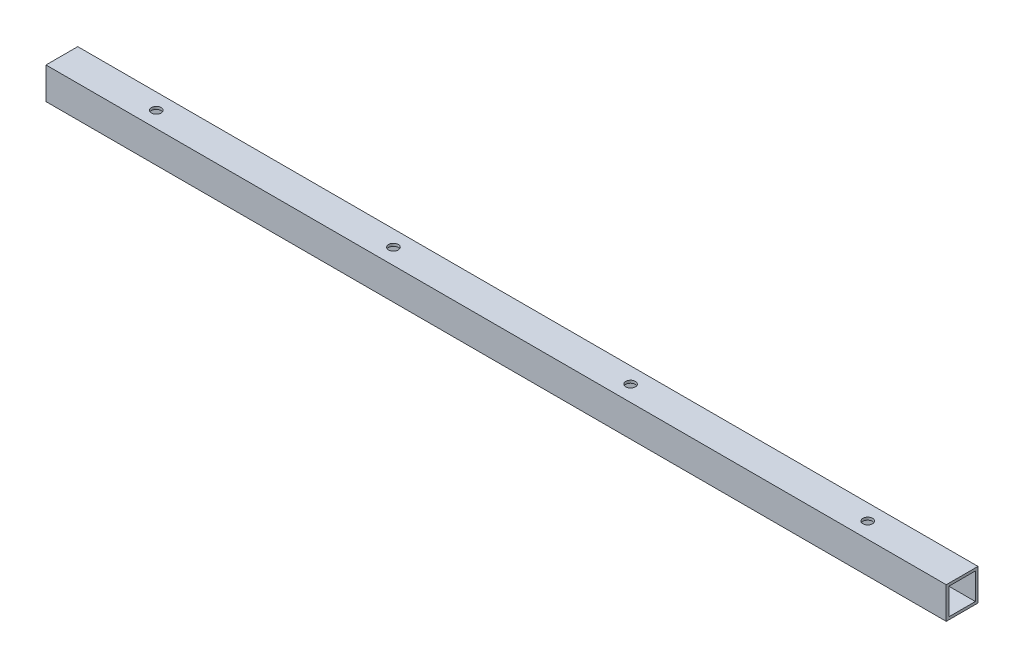
from build123d import *

# Parameters (mm, degrees)
SKETCH1_W               = 19.05
SKETCH1_H               = 19.05
SKETCH1_W_2             = 15.875
SKETCH1_H_2             = 15.875
TUBE_DEPTH              = 539.9532
SKETCH3_R               = 2.8956
REARTOPHOLEMASTER_DEPTH = 20.05
LPATTERN2_COUNT         = 4
LPATTERN2_PITCH         = 142.24


with BuildPart() as part:
    # Sketch1 → Tube (new body)
    with BuildSketch(Plane(origin=(0, 0, 0), x_dir=(0, -1, 0), z_dir=(1, 0, 0))):
        Rectangle(SKETCH1_W, SKETCH1_H)
        Rectangle(SKETCH1_W_2, SKETCH1_H_2, mode=Mode.SUBTRACT)
    extrude(amount=TUBE_DEPTH)

    # Sketch3 → RearTopHoleMaster (cut, through all)
    with BuildSketch(Plane(origin=(0, 9.525, 0), x_dir=(1, 0, 0), z_dir=(0, 1, 0))):
        with Locations((56.6166, 0)):
            Circle(SKETCH3_R)
    reartopholemaster = extrude(amount=-REARTOPHOLEMASTER_DEPTH, mode=Mode.SUBTRACT)

    # LPattern2: RearTopHoleMaster ×4
    with Locations(*[(i * LPATTERN2_PITCH, 0, 0) for i in range(1, LPATTERN2_COUNT)]):
        add(reartopholemaster, mode=Mode.SUBTRACT)


solid = part.part
